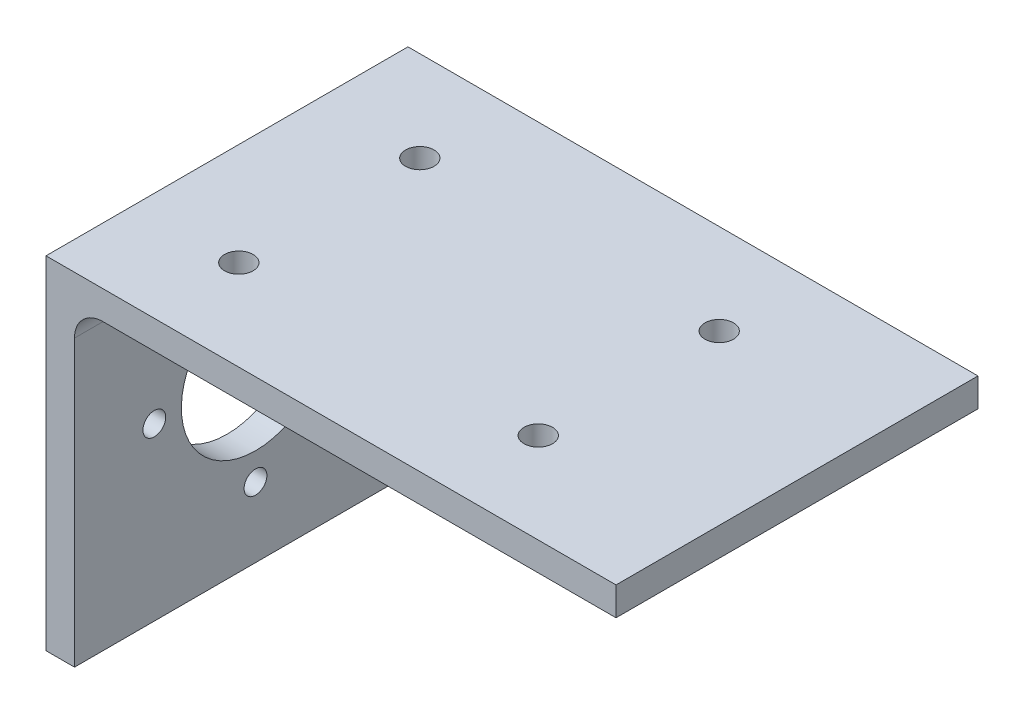
from build123d import *

# Parameters (mm, degrees)
BOSS_EXTRUDE1_DEPTH = 63.5
SKETCH2_R           = 13
SKETCH2_R_2         = 2
CUT_EXTRUDE1_DEPTH  = 5
SKETCH4_R           = 2.5
CUT_EXTRUDE3_DEPTH  = 10


with BuildPart() as part:
    # Sketch1 → Boss-Extrude1 (new body)
    with BuildSketch(Plane.XY):
        with BuildLine():
            Line((0, 0), (0, 60))
            Line((0, 60), (100, 60))
            Line((100, 60), (100, 55))
            Line((100, 55), (10, 55))
            ThreePointArc((10, 55), (6.464466094, 53.535533906), (5, 50))
            Line((5, 50), (5, 0))
            Line((5, 0), (0, 0))
        make_face()
    extrude(amount=BOSS_EXTRUDE1_DEPTH)

    # Sketch2 → Cut-Extrude1 (cut)
    with BuildSketch(Plane.ZY):
        with Locations((31.75, 30)):
            Circle(SKETCH2_R)
        with Locations((49.5, 30)):
            Circle(SKETCH2_R_2)
        with Locations((31.75, 12.25)):
            Circle(SKETCH2_R_2)
        with Locations((14, 30)):
            Circle(SKETCH2_R_2)
        with Locations((31.75, 47.75)):
            Circle(SKETCH2_R_2)
    extrude(amount=-CUT_EXTRUDE1_DEPTH, mode=Mode.SUBTRACT)

    # Sketch4 → Cut-Extrude3 (cut)
    with BuildSketch(Plane(origin=(0, 60, 0), x_dir=(1, 0, 0), z_dir=(0, 1, 0))):
        with Locations((70.47984065, -47.625)):
            Circle(SKETCH4_R)
        with Locations((17.94984065, -47.625)):
            Circle(SKETCH4_R)
        with Locations((17.94984065, -15.875)):
            Circle(SKETCH4_R)
        with Locations((70.47984065, -15.875)):
            Circle(SKETCH4_R)
    extrude(amount=-CUT_EXTRUDE3_DEPTH, mode=Mode.SUBTRACT)


solid = part.part
